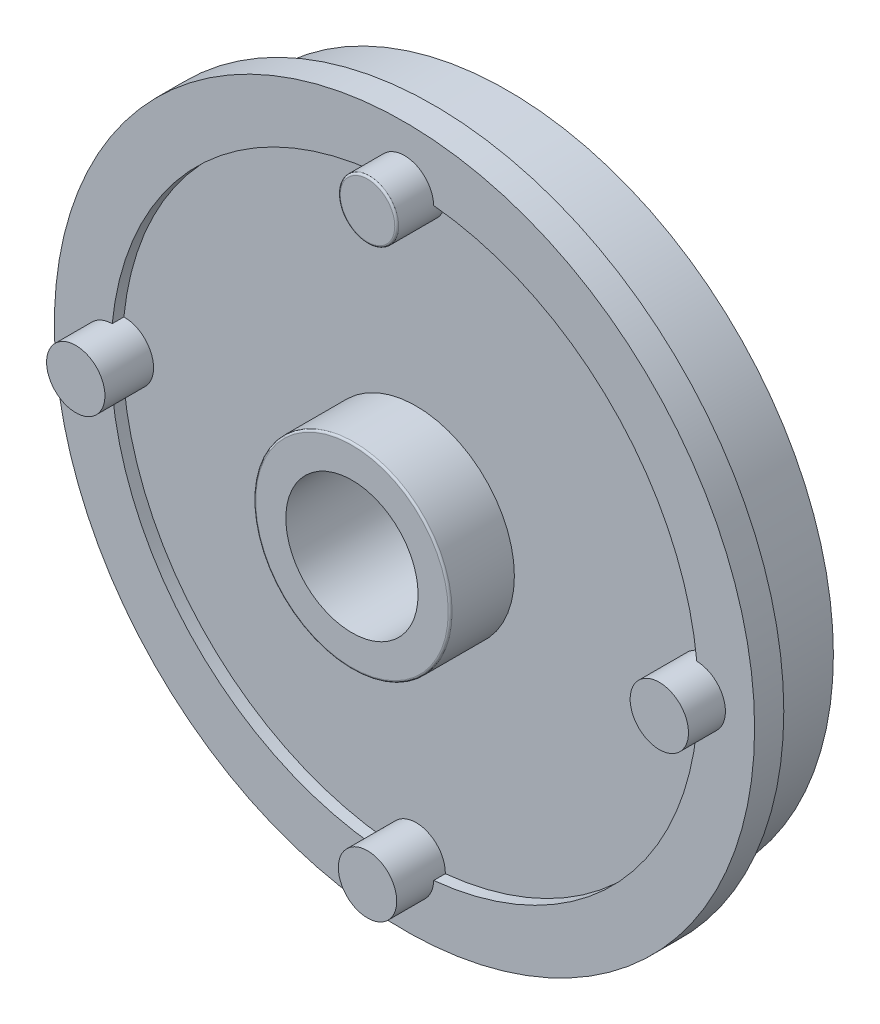
from build123d import *

# Parameters (mm, degrees)
SKETCH1_R           = 16.75
BOSS_EXTRUDE1_DEPTH = 3.8
SKETCH2_R           = 18
BOSS_EXTRUDE2_DEPTH = 1.5
SKETCH3_R           = 13.25
CUT_EXTRUDE1_DEPTH  = 4
SKETCH4_R           = 5
BOSS_EXTRUDE3_DEPTH = 6.5
SKETCH5_R           = 4
CUT_EXTRUDE2_DEPTH  = 2
SKETCH7_R           = 15.1
CUT_EXTRUDE3_DEPTH  = 0.6
SKETCH8_R           = 5.05
BOSS_EXTRUDE4_DEPTH = 3.3
SKETCH6_R           = 2.65
CUT_EXTRUDE4_DEPTH  = 9.5
SKETCH9_R           = 3.4
CUT_EXTRUDE5_DEPTH  = 7
SKETCH10_R          = 1.5
BOSS_EXTRUDE5_DEPTH = 2.5
FILLET2_R           = 0.1
FILLET3_R           = 0.1
CIRPATTERN1_COUNT   = 4


with BuildPart() as part:
    # Sketch1 → Boss-Extrude1 (new body)
    with BuildSketch(Plane.XY):
        Circle(SKETCH1_R)
    extrude(amount=BOSS_EXTRUDE1_DEPTH)

    # Sketch2 → Boss-Extrude2 (add)
    with BuildSketch(Plane.XY.offset(3.8)):
        Circle(SKETCH2_R)
    extrude(amount=BOSS_EXTRUDE2_DEPTH)

    # Sketch3 → Cut-Extrude1 (cut)
    with BuildSketch(Plane(origin=(0, 0, 0), x_dir=(-1, 0, 0), z_dir=(0, 0, -1))):
        Circle(SKETCH3_R)
    extrude(amount=-CUT_EXTRUDE1_DEPTH, mode=Mode.SUBTRACT)

    # Sketch4 → Boss-Extrude3 (add)
    with BuildSketch(Plane(origin=(0, 0, 4), x_dir=(-1, 0, 0), z_dir=(0, 0, -1))):
        Circle(SKETCH4_R)
    extrude(amount=BOSS_EXTRUDE3_DEPTH)

    # Sketch5 → Cut-Extrude2 (cut)
    with BuildSketch(Plane(origin=(0, 0, -2.5), x_dir=(-1, 0, 0), z_dir=(0, 0, -1))):
        Circle(SKETCH5_R)
    extrude(amount=-CUT_EXTRUDE2_DEPTH, mode=Mode.SUBTRACT)

    # Sketch7 → Cut-Extrude3 (cut)
    with BuildSketch(Plane.XY.offset(5.3)):
        Circle(SKETCH7_R)
    extrude(amount=-CUT_EXTRUDE3_DEPTH, mode=Mode.SUBTRACT)

    # Sketch8 → Boss-Extrude4 (add)
    with BuildSketch(Plane.XY.offset(4.7)):
        Circle(SKETCH8_R)
    extrude(amount=BOSS_EXTRUDE4_DEPTH)

    # Sketch6 → Cut-Extrude4 (cut, through all)
    with BuildSketch(Plane(origin=(0, 0, -0.5), x_dir=(-1, 0, 0), z_dir=(0, 0, -1))):
        Circle(SKETCH6_R)
    extrude(amount=-CUT_EXTRUDE4_DEPTH, mode=Mode.SUBTRACT)

    # Sketch9 → Cut-Extrude5 (cut)
    with BuildSketch(Plane.XY.offset(8)):
        Circle(SKETCH9_R)
    extrude(amount=-CUT_EXTRUDE5_DEPTH, mode=Mode.SUBTRACT)

    # Sketch10 → Boss-Extrude5 (add)
    with BuildSketch(Plane.XY.offset(4.7)):
        with Locations((0, 15)):
            Circle(SKETCH10_R)
    boss_extrude5 = extrude(amount=BOSS_EXTRUDE5_DEPTH)

    # Fillet2
    fillet2_edges = [part.edges().sort_by_distance(p)[0] for p in [
        (-1.5, 15, 7.2),
    ]]
    fillet(fillet2_edges, radius=FILLET2_R)

    # Fillet3
    fillet3_edges = [part.edges().sort_by_distance(p)[0] for p in [
        (-5.05, 0, 8),
    ]]
    fillet(fillet3_edges, radius=FILLET3_R)

    # CirPattern1: Boss-Extrude5 ×4 about axis
    cirpattern1_axis = Axis((0, 0, 0), (0, 0, 1))
    for i in range(1, CIRPATTERN1_COUNT):
        add(boss_extrude5.rotate(cirpattern1_axis, i * 360 / CIRPATTERN1_COUNT))


solid = part.part
